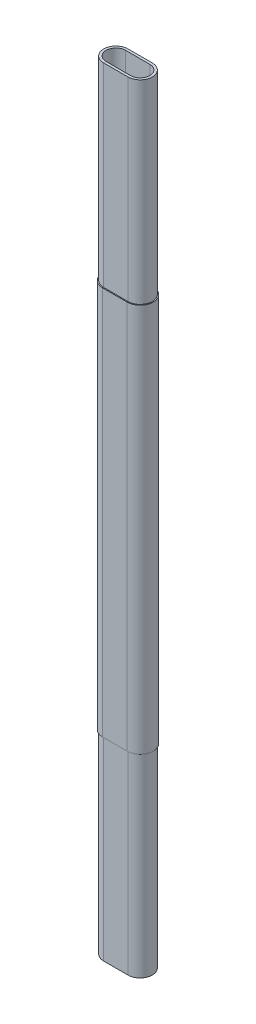
from build123d import *

# Parameters (mm, degrees)
EXTRUDE_THIN2_DEPTH      = 8
EXTRUDE_THIN2_DEPTH_BACK = 8
EXTRUDE_THIN4_DEPTH      = 4
EXTRUDE_THIN4_DEPTH_BACK = 4


with BuildPart() as part:
    # Sketch1 → Extrude-Thin2 (new body, two sides)
    with BuildSketch(Plane(origin=(0, 0, 0), x_dir=(1, 0, 0), z_dir=(0, 1, 0))) as extrude_thin2_sk:
        with BuildLine():
            Line((0.25, -0.25), (-0.25, -0.25))
            ThreePointArc((-0.25, -0.25), (-0.5, 0), (-0.25, 0.25))
            Line((-0.25, 0.25), (0.25, 0.25))
            ThreePointArc((0.25, 0.25), (0.5, 0), (0.25, -0.25))
        make_face()
        with BuildLine():
            Line((0.25, -0.2), (-0.25, -0.2))
            ThreePointArc((-0.25, -0.2), (-0.45, 0), (-0.25, 0.2))
            Line((-0.25, 0.2), (0.25, 0.2))
            ThreePointArc((0.25, 0.2), (0.45, 0), (0.25, -0.2))
        make_face(mode=Mode.SUBTRACT)
    extrude(amount=EXTRUDE_THIN2_DEPTH)
    extrude(extrude_thin2_sk.sketch, amount=-EXTRUDE_THIN2_DEPTH_BACK)

    # Sketch2 → Extrude-Thin4 (add, two sides)
    with BuildSketch(Plane(origin=(0, 0, 0), x_dir=(-1, 0, 0), z_dir=(0, 1, 0))) as extrude_thin4_sk:
        with BuildLine():
            Line((-0.25, -0.27), (0.25, -0.27))
            ThreePointArc((0.25, -0.27), (0.52, 0), (0.25, 0.27))
            Line((0.25, 0.27), (-0.25, 0.27))
            ThreePointArc((-0.25, 0.27), (-0.52, 0), (-0.25, -0.27))
        make_face()
        with BuildLine():
            Line((-0.25, -0.25), (0.25, -0.25))
            ThreePointArc((0.25, -0.25), (0.5, 0), (0.25, 0.25))
            Line((0.25, 0.25), (-0.25, 0.25))
            ThreePointArc((-0.25, 0.25), (-0.5, 0), (-0.25, -0.25))
        make_face(mode=Mode.SUBTRACT)
    extrude(amount=EXTRUDE_THIN4_DEPTH)
    extrude(extrude_thin4_sk.sketch, amount=-EXTRUDE_THIN4_DEPTH_BACK)


solid = part.part
